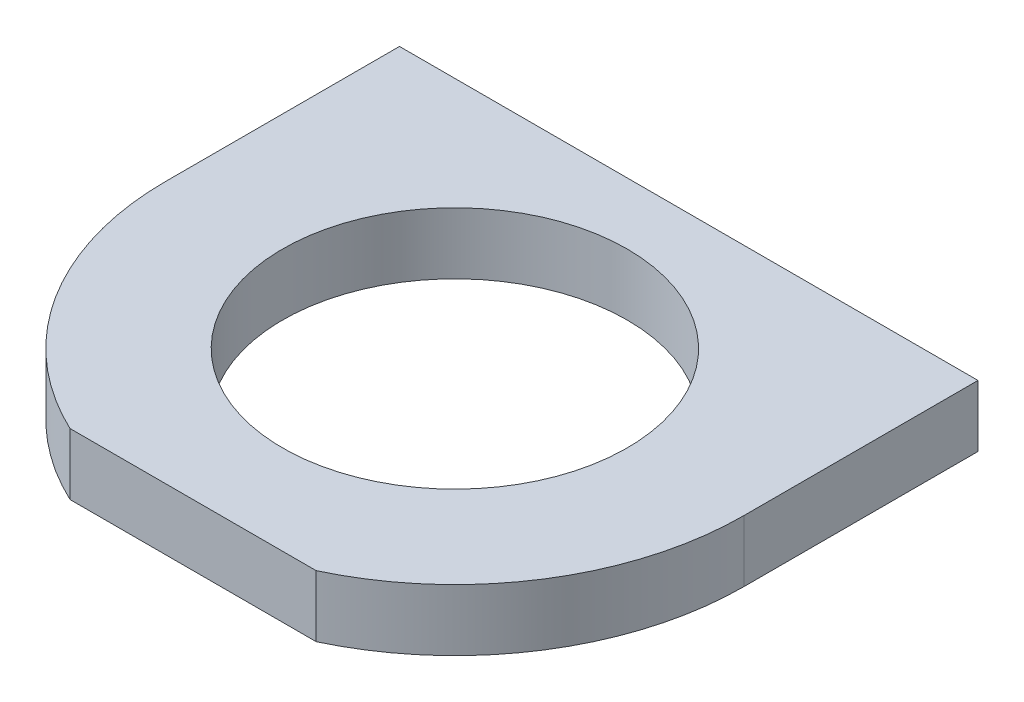
from build123d import *

# Parameters (mm, degrees)
SKETCH_1_W               = 47
SKETCH_1_H               = 5
EXTRUDE_1_DEPTH          = 19
SKETCH_2_R               = 23.5
EXTRUDE_2_DEPTH          = 5
M2_5X0_45_1_D            = 2.05
M2_5X0_45_1_DEPTH        = 7.25
M2_5X0_45_1_TIP          = 0.615882135
CUT_EXTRUDE_1_DEPTH      = 5
CUT_EXTRUDE_2_DEPTH      = 1
CUT_EXTRUDE_2_DEPTH_BACK = 6
CUT_EXTRUDE_3_DEPTH      = 5


with BuildPart() as part:
    # ｽｹｯﾁ1 → ﾎﾞｽ - 押し出し1 (new body)
    with BuildSketch(Plane.XY):
        Rectangle(SKETCH_1_W, SKETCH_1_H)
    extrude(amount=EXTRUDE_1_DEPTH)

    # ｽｹｯﾁ2 → ﾎﾞｽ - 押し出し2 (add)
    with BuildSketch(Plane.XZ.offset(2.5)):
        with Locations((0, 19)):
            Circle(SKETCH_2_R)
    extrude(amount=-EXTRUDE_2_DEPTH)

    # M2.5x0.45 ねじ穴1
    with Locations(Plane(origin=(0, 0, 0), x_dir=(-1, 0, 0), z_dir=(0, 0, -1))):
        with Locations((18, 0), (-18, 0)):
            Hole(M2_5X0_45_1_D / 2, depth=M2_5X0_45_1_DEPTH)
            with Locations((0, 0, -(M2_5X0_45_1_DEPTH + M2_5X0_45_1_TIP / 2))):  # 118° drill point
                Cone(0, M2_5X0_45_1_D / 2, M2_5X0_45_1_TIP, mode=Mode.SUBTRACT)

    # ｽｹｯﾁ3 → ｶｯﾄ - 押し出し1 (cut)
    with BuildSketch(Plane.XZ.offset(2.5)):
        with BuildLine():
            Line((14, 19), (0, 19))
            Line((0, 19), (-14, 19))
            ThreePointArc((-14, 19), (0, 5), (14, 19))
        make_face()
        with BuildLine():
            Line((-14, 19), (0, 19))
            Line((0, 19), (14, 19))
            ThreePointArc((14, 19), (0, 33), (-14, 19))
        make_face()
    extrude(amount=-CUT_EXTRUDE_1_DEPTH, mode=Mode.SUBTRACT)

    # ｽｹｯﾁ10 → ｶｯﾄ - 押し出し2 (cut, two sides)
    with BuildSketch(Plane.XZ.offset(2.5)) as cut_extrude_2_sk:
        Polygon((136.961591201, 0), (13.829316686, 0), (-13.829316686, 0), (-136.961591201, 0), (-136.961591201, -246.26454903), (136.961591201, -246.26454903), align=None)
    extrude(amount=CUT_EXTRUDE_2_DEPTH, mode=Mode.SUBTRACT)
    extrude(cut_extrude_2_sk.sketch, amount=-CUT_EXTRUDE_2_DEPTH_BACK, mode=Mode.SUBTRACT)

    # ｽｹｯﾁ11 → ｶｯﾄ - 押し出し3 (cut)
    with BuildSketch(Plane(origin=(0, 2.5, 0), x_dir=(1, 0, 0), z_dir=(0, 1, 0))):
        with BuildLine():
            Line((-10, -40.266170318), (10, -40.266170318))
            ThreePointArc((10, -40.266170318), (0, -42.5), (-10, -40.266170318))
        make_face()
    extrude(amount=-CUT_EXTRUDE_3_DEPTH, mode=Mode.SUBTRACT)


solid = part.part
